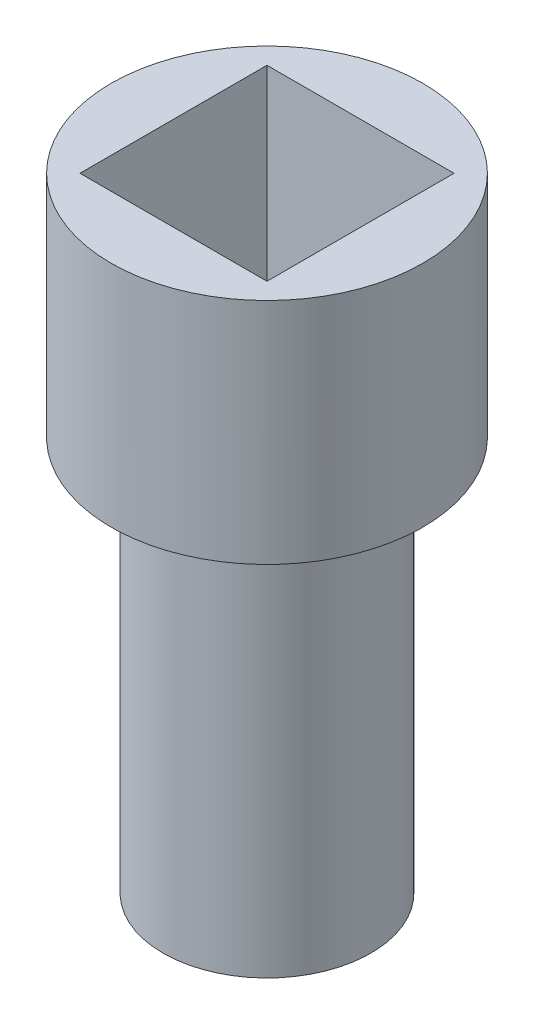
from build123d import *

# Parameters (mm, degrees)
SKETCH2_R           = 7.5
SKETCH2_W           = 9
SKETCH2_H           = 9
BOSS_EXTRUDE1_DEPTH = 10
SKETCH2_4_R         = 5
BOSS_EXTRUDE2_DEPTH = 20
SKETCH3_R           = 2
CUT_EXTRUDE1_DEPTH  = 8.5
BOSS_EXTRUDE3_START = 1
SKETCH4_R           = 7.5
BOSS_EXTRUDE3_DEPTH = 1


with BuildPart() as part:
    # Sketch2 → Boss-Extrude1 (new body)
    with BuildSketch(Plane(origin=(0, 0, 0), x_dir=(1, 0, 0), z_dir=(0, 1, 0))):
        Circle(SKETCH2_R)
        Rectangle(SKETCH2_W, SKETCH2_H, mode=Mode.SUBTRACT)
    extrude(amount=BOSS_EXTRUDE1_DEPTH)

    # Sketch2_4 → Boss-Extrude2 (add)
    with BuildSketch(Plane(origin=(0, 0, 0), x_dir=(1, 0, 0), z_dir=(0, 1, 0))):
        Circle(SKETCH2_4_R)
    extrude(amount=-BOSS_EXTRUDE2_DEPTH)

    # Sketch3 → Cut-Extrude1 (cut)
    with BuildSketch(Plane.XZ.offset(20)):
        Circle(SKETCH3_R)
    extrude(amount=-CUT_EXTRUDE1_DEPTH, mode=Mode.SUBTRACT)

    # Sketch4 → Boss-Extrude3 (add)
    with BuildSketch(Plane.XZ.offset(BOSS_EXTRUDE3_START)):
        Circle(SKETCH4_R)
    extrude(amount=-BOSS_EXTRUDE3_DEPTH)


solid = part.part
